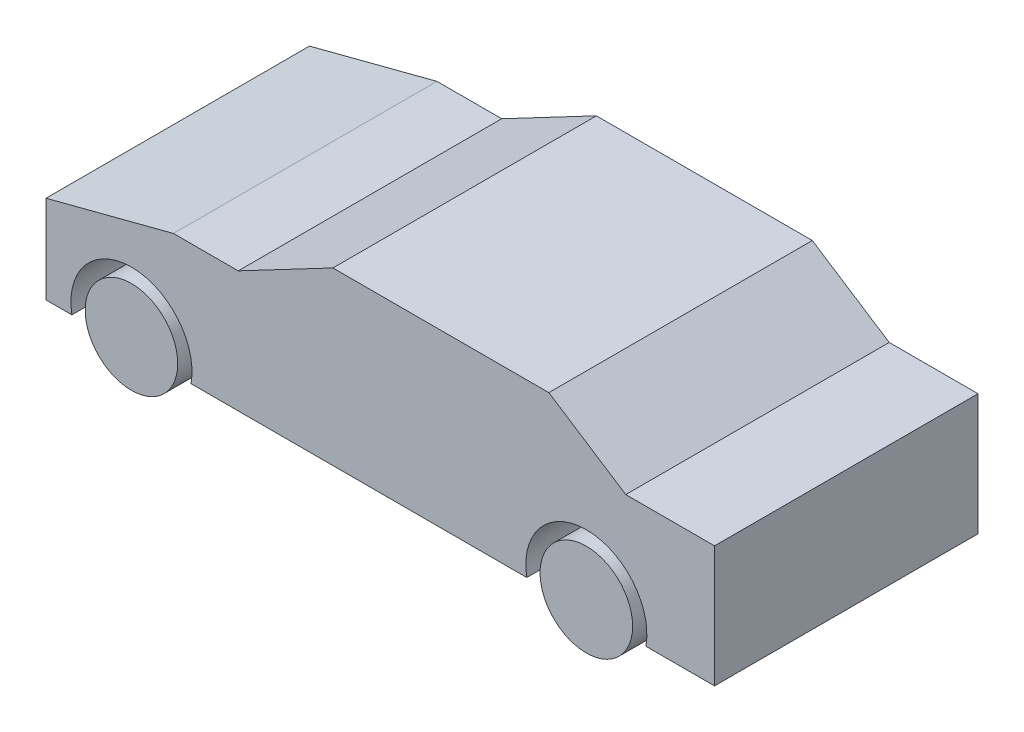
from build123d import *

# Parameters (mm, degrees)
BOSS_EXTRUDE1_DEPTH   = 1850
SKETCH1_R             = 325
BOSS_EXTRUDE1_2_DEPTH = 1850
BOSS_EXTRUDE1_3_DEPTH = 1850


with BuildPart() as part:
    # Sketch1 → Boss-Extrude1 (new body)
    with BuildSketch(Plane.XY):
        with BuildLine():
            ThreePointArc((4212.330013267, -1193), (3794, -693), (3375.669986733, -1193))
            Line((3375.669986733, -1193), (1018.330013267, -1193))
            ThreePointArc((1018.330013267, -1193), (600, -693), (181.669986733, -1193))
            Line((181.669986733, -1193), (0, -1193))
            Line((0, -1193), (0, -574.300771888))
            Line((0, -574.300771888), (895.308793073, -341.186371335))
            Line((895.308793073, -341.186371335), (1349.787903831, -341.186371335))
            Line((1349.787903831, -341.186371335), (2014.430951703, 8.813628665))
            Line((2014.430951703, 8.813628665), (3530.647904664, 8.813628665))
            Line((3530.647904664, 8.813628665), (4070.67038106, -341.186371335))
            Line((4070.67038106, -341.186371335), (4694, -341.186371335))
            Line((4694, -341.186371335), (4694, -1193))
            Line((4694, -1193), (4212.330013267, -1193))
        make_face()
    extrude(amount=BOSS_EXTRUDE1_DEPTH)


with BuildPart() as body_2:
    # Sketch1 → Boss-Extrude1 2 (new body)
    with BuildSketch(Plane.XY):
        with Locations((600, -1118)):
            Circle(SKETCH1_R)
    extrude(amount=BOSS_EXTRUDE1_2_DEPTH)


with BuildPart() as body_3:
    # Sketch1 → Boss-Extrude1 3 (new body)
    with BuildSketch(Plane.XY):
        with Locations((3794, -1118)):
            Circle(SKETCH1_R)
    extrude(amount=BOSS_EXTRUDE1_3_DEPTH)


solid = Compound([part.part, body_2.part, body_3.part])
